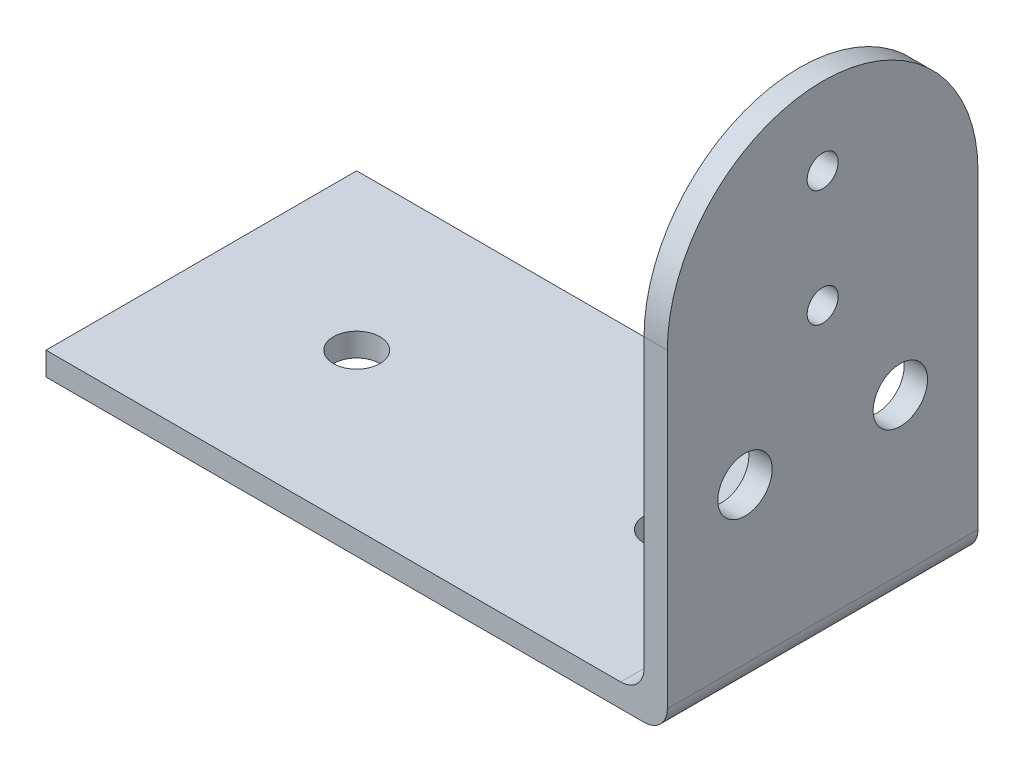
from build123d import *

# Parameters (mm, degrees)
SKETCH2_W           = 80
SKETCH2_H           = 40
BOSS_EXTRUDE1_DEPTH = 3
SKETCH2_3_W         = 3
SKETCH2_3_H         = 40
BOSS_EXTRUDE2_DEPTH = 60
FILLET1_R           = 3
SKETCH3_R           = 2
SKETCH3_R_2         = 3.5
CUT_EXTRUDE1_DEPTH  = 108.703296143
SKETCH7_R           = 3
CUT_EXTRUDE2_DEPTH  = 110.402925007


with BuildPart() as part:
    # Sketch2 → Boss-Extrude1 (new body)
    with BuildSketch(Plane(origin=(0, 0, 0), x_dir=(1, 0, 0), z_dir=(0, 1, 0))):
        with Locations((40, 20)):
            Rectangle(SKETCH2_W, SKETCH2_H)
    extrude(amount=-BOSS_EXTRUDE1_DEPTH)

    # Sketch2_3 → Boss-Extrude2 (add)
    with BuildSketch(Plane(origin=(0, 0, 0), x_dir=(1, 0, 0), z_dir=(0, 1, 0))):
        with Locations((78.5, 20)):
            Rectangle(SKETCH2_3_W, SKETCH2_3_H)
    extrude(amount=BOSS_EXTRUDE2_DEPTH)

    # Fillet1
    fillet1_edges = [part.edges().sort_by_distance(p)[0] for p in [
        (80, -3, -20),
        (77, 0, -20),
    ]]
    fillet(fillet1_edges, radius=FILLET1_R)

    # Sketch3 → Cut-Extrude1 (cut, through all)
    with BuildSketch(Plane(origin=(80, 0, 0), x_dir=(0, 0, -1), z_dir=(1, 0, 0))):
        with Locations((20, 35)):
            Circle(SKETCH3_R)
        with Locations((20, 50)):
            Circle(SKETCH3_R)
        with BuildLine():
            ThreePointArc((0, 40), (5.857864376, 54.142135624), (20, 60))
            Line((20, 60), (0, 60))
            Line((0, 60), (0, 40))
        make_face()
        with BuildLine():
            Line((40, 60), (20, 60))
            ThreePointArc((20, 60), (34.142135624, 54.142135624), (40, 40))
            Line((40, 40), (40, 60))
        make_face()
        with Locations((10, 20)):
            Circle(SKETCH3_R_2)
        with Locations((30, 20)):
            Circle(SKETCH3_R_2)
    extrude(amount=-CUT_EXTRUDE1_DEPTH, mode=Mode.SUBTRACT)

    # Sketch7 → Cut-Extrude2 (cut, through all)
    with BuildSketch(Plane.XZ.offset(3)):
        with Locations((60, -20)):
            Circle(SKETCH7_R)
        with Locations((20, -20)):
            Circle(SKETCH7_R)
    extrude(amount=-CUT_EXTRUDE2_DEPTH, mode=Mode.SUBTRACT)


solid = part.part
